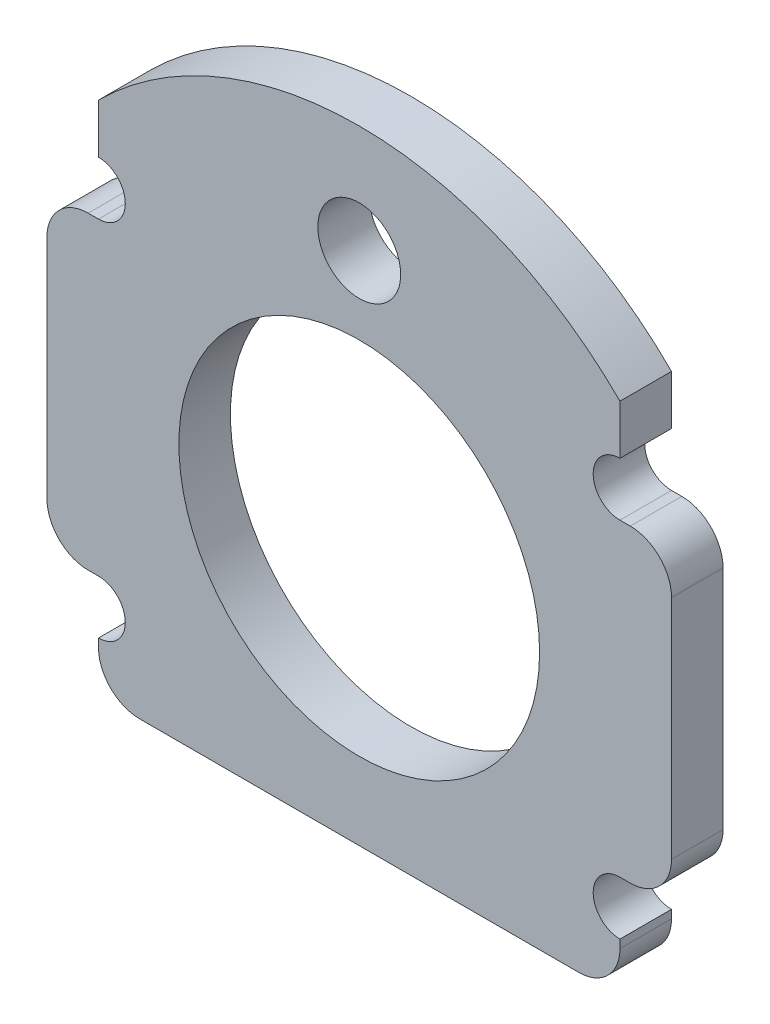
from build123d import *

# Parameters (mm, degrees)
SKETCH1_R           = 11.1125
BOSS_EXTRUDE1_DEPTH = 3.175
BOSS_EXTRUDE3_DEPTH = 3.175
SKETCH4_R           = 2.5527
CUT_EXTRUDE2_DEPTH  = 4.175
FILLET1_R           = 2.54
CUT_EXTRUDE1_DEPTH  = 4.175


with BuildPart() as part:
    # Sketch1 → Boss-Extrude1 (new body)
    with BuildSketch(Plane.XY):
        Polygon((-19.2405, -9.525), (-19.2405, 9.525), (-16.0655, 9.525), (-16.0655, 15.875), (16.0655, 15.875), (16.0655, 9.525), (19.2405, 9.525), (19.2405, -9.525), (16.0655, -9.525), (16.0655, -15.875), (-16.0655, -15.875), (-16.0655, -9.525), align=None)
        Circle(SKETCH1_R, mode=Mode.SUBTRACT)
    extrude(amount=BOSS_EXTRUDE1_DEPTH)

    # Sketch3 → Boss-Extrude3 (add)
    with BuildSketch(Plane.XY.offset(3.175)):
        with BuildLine():
            Line((-16.0655, 15.875), (16.0655, 15.875))
            ThreePointArc((16.0655, 15.875), (0, 22.529547986), (-16.0655, 15.875))
        make_face()
    extrude(amount=-BOSS_EXTRUDE3_DEPTH)

    # Sketch4 → Cut-Extrude2 (cut, through all)
    with BuildSketch(Plane(origin=(0, 0, 0), x_dir=(-1, 0, 0), z_dir=(0, 0, -1))):
        with Locations((0, 15.875)):
            Circle(SKETCH4_R)
    extrude(amount=-CUT_EXTRUDE2_DEPTH, mode=Mode.SUBTRACT)

    # Fillet1
    fillet1_edges = [part.edges().sort_by_distance(p)[0] for p in [
        (19.2405, 9.525, 1.5875),
        (19.2405, -9.525, 1.5875),
        (16.0655, -15.875, 1.5875),
        (-16.0655, -15.875, 1.5875),
        (-19.2405, -9.525, 1.5875),
        (-19.2405, 9.525, 1.5875),
    ]]
    fillet(fillet1_edges, radius=FILLET1_R)

    # Sketch2 → Cut-Extrude1 (cut, through all)
    with BuildSketch(Plane.XY.offset(3.175)):
        with BuildLine():
            Line((-16.0655, -9.525), (-16.0655, -12.827))
            ThreePointArc((-16.0655, -12.827), (-14.4145, -11.176), (-16.0655, -9.525))
        make_face()
        with BuildLine():
            Line((16.0655, -9.525), (16.0655, -12.827))
            ThreePointArc((16.0655, -12.827), (14.4145, -11.176), (16.0655, -9.525))
        make_face()
        with BuildLine():
            Line((-16.0655, 9.525), (-16.0655, 12.827))
            ThreePointArc((-16.0655, 12.827), (-14.4145, 11.176), (-16.0655, 9.525))
        make_face()
        with BuildLine():
            Line((16.0655, 9.525), (16.0655, 12.827))
            ThreePointArc((16.0655, 12.827), (14.4145, 11.176), (16.0655, 9.525))
        make_face()
    extrude(amount=-CUT_EXTRUDE1_DEPTH, mode=Mode.SUBTRACT)


solid = part.part
